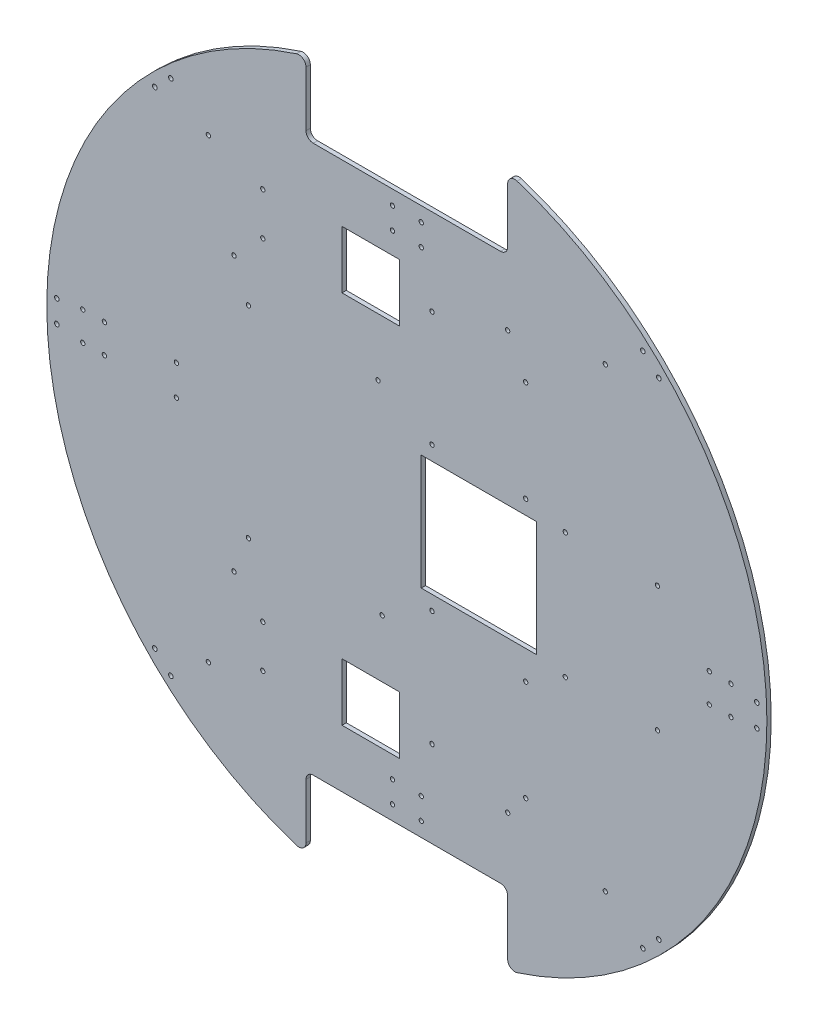
from build123d import *

# Parameters (mm, degrees)
SKETCH_1_R           = 250
EXTRUDE_1_DEPTH      = 3
CUT_EXTRUDE_1_DEPTH  = 4
CUT_EXTRUDE_2_DEPTH  = 4
FILLET_1_R           = 5
FILLET_2_R           = 5
FILLET_3_R           = 5
FILLET_4_R           = 5
FILLET_5_R           = 5
FILLET_6_R           = 5
FILLET_7_R           = 5
FILLET_8_R           = 5
SKETCH_18_R          = 1.5
CUT_EXTRUDE_10_DEPTH = 4
SKETCH_19_R          = 1.5
CUT_EXTRUDE_11_DEPTH = 3
SKETCH_20_R          = 1.6
CUT_EXTRUDE_12_DEPTH = 4
SKETCH_24_R          = 1.5
CUT_EXTRUDE_14_DEPTH = 4
SKETCH_25_R          = 1.5
CUT_EXTRUDE_15_DEPTH = 4
SKETCH_21_R          = 1.5
CUT_EXTRUDE_16_DEPTH = 4
SKETCH_26_R          = 1.6
CUT_EXTRUDE_17_DEPTH = 4
SKETCH_27_R          = 1.5
CUT_EXTRUDE_18_DEPTH = 4
SKETCH_28_R          = 1.5
CUT_EXTRUDE_19_DEPTH = 4
SKETCH_29_W          = 40
SKETCH_29_H          = 40
CUT_EXTRUDE_20_DEPTH = 4
SKETCH_30_R          = 1.5
CUT_EXTRUDE_21_DEPTH = 4
SKETCH_31_R          = 1.5
CUT_EXTRUDE_22_DEPTH = 4
SKETCH_32_R          = 1.5
CUT_EXTRUDE_23_DEPTH = 4


with BuildPart() as part:
    # ｽｹｯﾁ1 → ﾎﾞｽ - 押し出し1 (new body)
    with BuildSketch(Plane.XY):
        Circle(SKETCH_1_R)
    extrude(amount=-EXTRUDE_1_DEPTH)

    # ｽｹｯﾁ2 → ｶｯﾄ - 押し出し1 (cut, through all)
    with BuildSketch(Plane.XY):
        Polygon((0, 190), (70, 190), (70, 250), (0, 250), (-70, 250), (-70, 190), align=None)
    extrude(amount=-CUT_EXTRUDE_1_DEPTH, mode=Mode.SUBTRACT)

    # ｽｹｯﾁ3 → ｶｯﾄ - 押し出し2 (cut, through all)
    with BuildSketch(Plane.XY):
        Polygon((0, -250), (70, -250), (70, -190), (0, -190), (-70, -190), (-70, -250), align=None)
    extrude(amount=-CUT_EXTRUDE_2_DEPTH, mode=Mode.SUBTRACT)

    # ﾌｨﾚｯﾄ1
    fillet_1_edges = [part.edges().sort_by_distance(p)[0] for p in [
        (-70, 240, -1.5),
    ]]
    fillet(fillet_1_edges, radius=FILLET_1_R)

    # ﾌｨﾚｯﾄ2
    fillet_2_edges = [part.edges().sort_by_distance(p)[0] for p in [
        (70, 240, -1.5),
    ]]
    fillet(fillet_2_edges, radius=FILLET_2_R)

    # ﾌｨﾚｯﾄ3
    fillet_3_edges = [part.edges().sort_by_distance(p)[0] for p in [
        (70, 190, -1.5),
    ]]
    fillet(fillet_3_edges, radius=FILLET_3_R)

    # ﾌｨﾚｯﾄ4
    fillet_4_edges = [part.edges().sort_by_distance(p)[0] for p in [
        (-70, 190, -1.5),
    ]]
    fillet(fillet_4_edges, radius=FILLET_4_R)

    # ﾌｨﾚｯﾄ5
    fillet_5_edges = [part.edges().sort_by_distance(p)[0] for p in [
        (-70, -240, -1.5),
    ]]
    fillet(fillet_5_edges, radius=FILLET_5_R)

    # ﾌｨﾚｯﾄ6
    fillet_6_edges = [part.edges().sort_by_distance(p)[0] for p in [
        (70, -190, -1.5),
    ]]
    fillet(fillet_6_edges, radius=FILLET_6_R)

    # ﾌｨﾚｯﾄ7
    fillet_7_edges = [part.edges().sort_by_distance(p)[0] for p in [
        (70, -240, -1.5),
    ]]
    fillet(fillet_7_edges, radius=FILLET_7_R)

    # ﾌｨﾚｯﾄ8
    fillet_8_edges = [part.edges().sort_by_distance(p)[0] for p in [
        (-70, -190, -1.5),
    ]]
    fillet(fillet_8_edges, radius=FILLET_8_R)

    # ｽｹｯﾁ18 → ｶｯﾄ - 押し出し10 (cut, through all)
    with BuildSketch(Plane.XY):
        with Locations((-100, 144.75)):
            Circle(SKETCH_18_R)
        with Locations((-100, 115.25)):
            Circle(SKETCH_18_R)
        with Locations((-100, -115.25)):
            Circle(SKETCH_18_R)
        with Locations((-100, -144.75)):
            Circle(SKETCH_18_R)
    extrude(amount=-CUT_EXTRUDE_10_DEPTH, mode=Mode.SUBTRACT)

    # ｽｹｯﾁ19 → ｶｯﾄ - 押し出し11 (cut)
    with BuildSketch(Plane.XY):
        with Locations((-160, 10.5)):
            Circle(SKETCH_19_R)
        with Locations((-160, -10.5)):
            Circle(SKETCH_19_R)
    extrude(amount=-CUT_EXTRUDE_11_DEPTH, mode=Mode.SUBTRACT)

    # ｽｹｯﾁ20 → ｶｯﾄ - 押し出し12 (cut, through all)
    with BuildSketch(Plane.XY):
        with Locations((-243, 7.75)):
            Circle(SKETCH_20_R)
        with Locations((-243, -7.75)):
            Circle(SKETCH_20_R)
        with Locations((-163.855062784, 179.612307206)):
            Circle(SKETCH_20_R)
        with Locations((-174.967177203, 168.806248112)):
            Circle(SKETCH_20_R)
        with Locations((-163.855062784, -179.612307206)):
            Circle(SKETCH_20_R)
        with Locations((-174.967177203, -168.806248112)):
            Circle(SKETCH_20_R)
    extrude(amount=-CUT_EXTRUDE_12_DEPTH, mode=Mode.SUBTRACT)

    # ｽｹｯﾁ24 → ｶｯﾄ - 押し出し14 (cut, through all)
    with BuildSketch(Plane.XY):
        with Locations((225, 10)):
            Circle(SKETCH_24_R)
        with Locations((225, -10)):
            Circle(SKETCH_24_R)
        with Locations((210, -10)):
            Circle(SKETCH_24_R)
        with Locations((210, 10)):
            Circle(SKETCH_24_R)
    extrude(amount=-CUT_EXTRUDE_14_DEPTH, mode=Mode.SUBTRACT)

    # ｽｹｯﾁ25 → ｶｯﾄ - 押し出し15 (cut, through all)
    with BuildSketch(Plane.XY):
        with Locations((-225, 10)):
            Circle(SKETCH_25_R)
        with Locations((-225, -10)):
            Circle(SKETCH_25_R)
        with Locations((-210, -10)):
            Circle(SKETCH_25_R)
        with Locations((-210, 10)):
            Circle(SKETCH_25_R)
    extrude(amount=-CUT_EXTRUDE_15_DEPTH, mode=Mode.SUBTRACT)

    # ｽｹｯﾁ21 → ｶｯﾄ - 押し出し16 (cut, through all)
    with BuildSketch(Plane.XY):
        with Locations((137.80005554, 158.464963614)):
            Circle(SKETCH_21_R)
        with Locations((137.80005554, -158.464963614)):
            Circle(SKETCH_21_R)
        with Locations((-137.80005554, -158.464963614)):
            Circle(SKETCH_21_R)
        with Locations((-137.80005554, 158.464963614)):
            Circle(SKETCH_21_R)
    extrude(amount=-CUT_EXTRUDE_16_DEPTH, mode=Mode.SUBTRACT)

    # ｽｹｯﾁ26 → ｶｯﾄ - 押し出し17 (cut, through all)
    with BuildSketch(Plane.XY):
        with Locations((174.967177203, -168.806248112)):
            Circle(SKETCH_26_R)
        with Locations((163.855062784, -179.612307206)):
            Circle(SKETCH_26_R)
        with Locations((243, -7.75)):
            Circle(SKETCH_26_R)
        with Locations((243, 7.75)):
            Circle(SKETCH_26_R)
        with Locations((174.967177203, 168.806248112)):
            Circle(SKETCH_26_R)
        with Locations((163.855062784, 179.612307206)):
            Circle(SKETCH_26_R)
    extrude(amount=-CUT_EXTRUDE_17_DEPTH, mode=Mode.SUBTRACT)

    # ｽｹｯﾁ27 → ｶｯﾄ - 押し出し18 (cut, through all)
    with BuildSketch(Plane.XY):
        with Locations((-10, 180)):
            Circle(SKETCH_27_R)
        with Locations((10, 180)):
            Circle(SKETCH_27_R)
        with Locations((10, 165)):
            Circle(SKETCH_27_R)
        with Locations((-10, 165)):
            Circle(SKETCH_27_R)
        with Locations((10, -180)):
            Circle(SKETCH_27_R)
        with Locations((10, -165)):
            Circle(SKETCH_27_R)
        with Locations((-10, -165)):
            Circle(SKETCH_27_R)
        with Locations((-10, -180)):
            Circle(SKETCH_27_R)
    extrude(amount=-CUT_EXTRUDE_18_DEPTH, mode=Mode.SUBTRACT)

    # ｽｹｯﾁ28 → ｶｯﾄ - 押し出し19 (cut, through all)
    with BuildSketch(Plane.XY):
        with Locations((17.5, 130)):
            Circle(SKETCH_28_R)
        with Locations((82.5, 120)):
            Circle(SKETCH_28_R)
        with Locations((17.5, 50)):
            Circle(SKETCH_28_R)
        with Locations((82.5, 50)):
            Circle(SKETCH_28_R)
        with Locations((17.5, -50)):
            Circle(SKETCH_28_R)
        with Locations((82.5, -60)):
            Circle(SKETCH_28_R)
        with Locations((17.5, -130)):
            Circle(SKETCH_28_R)
        with Locations((82.5, -130)):
            Circle(SKETCH_28_R)
        Polygon((10, 40), (90, 40), (90, 0), (90, -40), (10, -40), (10, 1.027968607), align=None)
    extrude(amount=-CUT_EXTRUDE_19_DEPTH, mode=Mode.SUBTRACT)

    # ｽｹｯﾁ29 → ｶｯﾄ - 押し出し20 (cut, through all)
    with BuildSketch(Plane.XY):
        with Locations((-25, -130)):
            Rectangle(SKETCH_29_W, SKETCH_29_H)
        with Locations((-25, 130)):
            Rectangle(SKETCH_29_W, SKETCH_29_H)
    extrude(amount=-CUT_EXTRUDE_20_DEPTH, mode=Mode.SUBTRACT)

    # ｽｹｯﾁ30 → ｶｯﾄ - 押し出し21 (cut, through all)
    with BuildSketch(Plane.XY):
        with Locations((110, 43.5)):
            Circle(SKETCH_30_R)
        with Locations((174, 43.5)):
            Circle(SKETCH_30_R)
        with Locations((110, -43.5)):
            Circle(SKETCH_30_R)
        with Locations((174, -43.5)):
            Circle(SKETCH_30_R)
    extrude(amount=-CUT_EXTRUDE_21_DEPTH, mode=Mode.SUBTRACT)

    # ｽｹｯﾁ31 → ｶｯﾄ - 押し出し22 (cut, through all)
    with BuildSketch(Plane.XY):
        with Locations((-20, 70)):
            Circle(SKETCH_31_R)
        with Locations((-110, 70)):
            Circle(SKETCH_31_R)
        with Locations((-110, -70)):
            Circle(SKETCH_31_R)
        with Locations((-17.141016151, -70)):
            Circle(SKETCH_31_R)
    extrude(amount=-CUT_EXTRUDE_22_DEPTH, mode=Mode.SUBTRACT)

    # ｽｹｯﾁ32 → ｶｯﾄ - 押し出し23 (cut, through all)
    with BuildSketch(Plane.XY):
        with Locations((-120, 95)):
            Circle(SKETCH_32_R)
        with Locations((-120, -95)):
            Circle(SKETCH_32_R)
        with Locations((70, 145)):
            Circle(SKETCH_32_R)
        with Locations((70, -145)):
            Circle(SKETCH_32_R)
    extrude(amount=-CUT_EXTRUDE_23_DEPTH, mode=Mode.SUBTRACT)


solid = part.part
